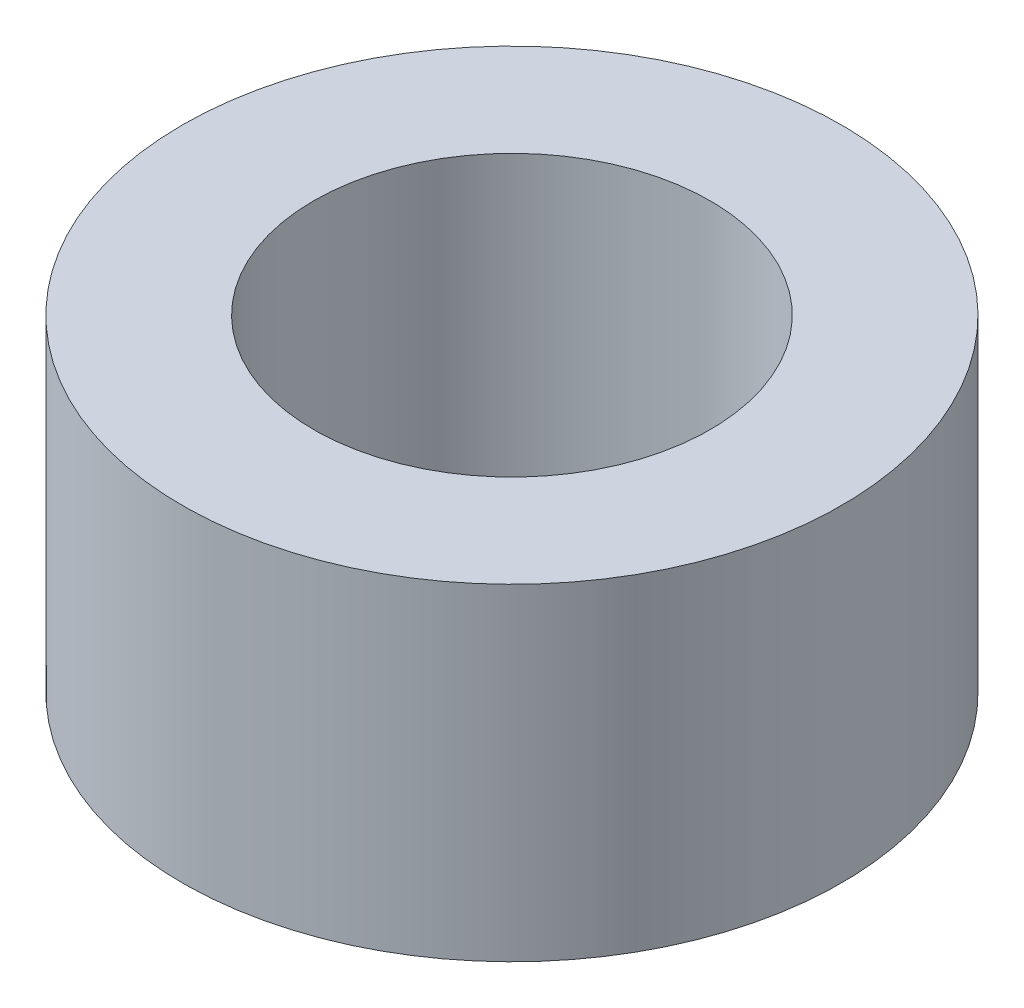
from build123d import *

# Parameters (mm, degrees)
SKETCH1_W           = 38.1
SKETCH1_H           = 38.1
SKETCH1_R           = 4
SKETCH1_R_2         = 1.5875
SKETCH1_R_3         = 1.25
BOSS_EXTRUDE1_DEPTH = 3.175
SKETCH4_R           = 1.7272
CUT_EXTRUDE2_DEPTH  = 10.795
SKETCH7_R           = 2.15265
CUT_EXTRUDE3_DEPTH  = 7.3500001
CIRPATTERN1_COUNT   = 4
SKETCH6_W           = 38.1
SKETCH6_H           = 38.1
SKETCH6_R           = 6.5
SKETCH6_R_2         = 2.15265
BOSS_EXTRUDE2_DEPTH = 3.175
FILLET1_R           = 2.54
FILLET2_R           = 2.54
SKETCH8_R           = 3.96875
SKETCH8_R_2         = 2.3876
BOSS_EXTRUDE3_DEPTH = 3.937
CIRPATTERN2_COUNT   = 4


with BuildPart() as part:
    # Sketch1 → Boss-Extrude1 (new body, symmetric)
    with BuildSketch(Plane(origin=(0, 0, 0), x_dir=(1, 0, 0), z_dir=(0, 1, 0))):
        Rectangle(SKETCH1_W, SKETCH1_H)
        Circle(SKETCH1_R, mode=Mode.SUBTRACT)
        with Locations((8.838834765, 8.838834765)):
            Circle(SKETCH1_R_2, mode=Mode.SUBTRACT)
        with Locations((8.838834765, -8.838834765)):
            Circle(SKETCH1_R_2, mode=Mode.SUBTRACT)
        with Locations((-8.838834765, -8.838834765)):
            Circle(SKETCH1_R_2, mode=Mode.SUBTRACT)
        with Locations((-8.838834765, 8.838834765)):
            Circle(SKETCH1_R_2, mode=Mode.SUBTRACT)
        with Locations((-14.5, 0)):
            Circle(SKETCH1_R_3, mode=Mode.SUBTRACT)
        with Locations((0, 14.5)):
            Circle(SKETCH1_R_3, mode=Mode.SUBTRACT)
        with Locations((14.5, 0)):
            Circle(SKETCH1_R_3, mode=Mode.SUBTRACT)
        with Locations((0, -14.5)):
            Circle(SKETCH1_R_3, mode=Mode.SUBTRACT)
    extrude(amount=BOSS_EXTRUDE1_DEPTH, both=True)

    # Sketch4 → Cut-Extrude2 (cut)
    with BuildSketch(Plane.XY.offset(19.05)):
        with Locations((-5.55625, 0)):
            Circle(SKETCH4_R)
        with Locations((5.55625, 0)):
            Circle(SKETCH4_R)
    cut_extrude2 = extrude(amount=-CUT_EXTRUDE2_DEPTH, mode=Mode.SUBTRACT)

    # Sketch7 → Cut-Extrude3 (cut, through all)
    with BuildSketch(Plane.XZ.offset(3.175)):
        with Locations((-15.08125, 15.08125)):
            Circle(SKETCH7_R)
        with Locations((15.08125, 15.08125)):
            Circle(SKETCH7_R)
        with Locations((15.08125, -15.08125)):
            Circle(SKETCH7_R)
        with Locations((-15.08125, -15.08125)):
            Circle(SKETCH7_R)
    extrude(amount=-CUT_EXTRUDE3_DEPTH, mode=Mode.SUBTRACT)

    # CirPattern1: Cut-Extrude2 ×4 about axis
    cirpattern1_axis = Axis((0, 0, 0), (0, 1, 0))
    for i in range(1, CIRPATTERN1_COUNT):
        add(cut_extrude2.rotate(cirpattern1_axis, i * 360 / CIRPATTERN1_COUNT), mode=Mode.SUBTRACT)

    # Fillet1
    fillet1_edges = [part.edges().sort_by_distance(p)[0] for p in [
        (19.05, 0, 19.05),
        (-19.05, 0, 19.05),
        (-19.05, 0, -19.05),
        (19.05, 0, -19.05),
    ]]
    fillet(fillet1_edges, radius=FILLET1_R)


with BuildPart() as body_2:
    # Sketch6 → Boss-Extrude2 (new body)
    with BuildSketch(Plane(origin=(0, -32.512, 0), x_dir=(-1, 0, 0), z_dir=(0, -1, 0))):
        Rectangle(SKETCH6_W, SKETCH6_H)
        Circle(SKETCH6_R, mode=Mode.SUBTRACT)
        with Locations((-15.08125, 15.08125)):
            Circle(SKETCH6_R_2, mode=Mode.SUBTRACT)
        with Locations((15.08125, 15.08125)):
            Circle(SKETCH6_R_2, mode=Mode.SUBTRACT)
        with Locations((15.08125, -15.08125)):
            Circle(SKETCH6_R_2, mode=Mode.SUBTRACT)
        with Locations((-15.08125, -15.08125)):
            Circle(SKETCH6_R_2, mode=Mode.SUBTRACT)
    extrude(amount=BOSS_EXTRUDE2_DEPTH)

    # Fillet2
    fillet2_edges = [body_2.edges().sort_by_distance(p)[0] for p in [
        (-19.05, -34.0995, 19.05),
        (19.05, -34.0995, 19.05),
        (19.05, -34.0995, -19.05),
        (-19.05, -34.0995, -19.05),
    ]]
    fillet(fillet2_edges, radius=FILLET2_R)


with BuildPart() as body_3:
    # Sketch8 → Boss-Extrude3 (new body)
    with BuildSketch(Plane(origin=(0, -32.512, 0), x_dir=(1, 0, 0), z_dir=(0, 1, 0))):
        with Locations((-15.08125, 15.08125)):
            Circle(SKETCH8_R)
        with Locations((-15.08125, 15.08125)):
            Circle(SKETCH8_R_2, mode=Mode.SUBTRACT)
    extrude(amount=BOSS_EXTRUDE3_DEPTH)


with BuildPart() as cirpattern2_1:
    # CirPattern2: pattern copy
    add(body_3.part.rotate(Axis((0, 0, 0), (0, 1, 0)), 1 * 360 / CIRPATTERN2_COUNT))


with BuildPart() as cirpattern2_2:
    # CirPattern2: pattern copy
    add(body_3.part.rotate(Axis((0, 0, 0), (0, 1, 0)), 2 * 360 / CIRPATTERN2_COUNT))


with BuildPart() as cirpattern2_3:
    # CirPattern2: pattern copy
    add(body_3.part.rotate(Axis((0, 0, 0), (0, 1, 0)), 3 * 360 / CIRPATTERN2_COUNT))


solid = cirpattern2_3.part
